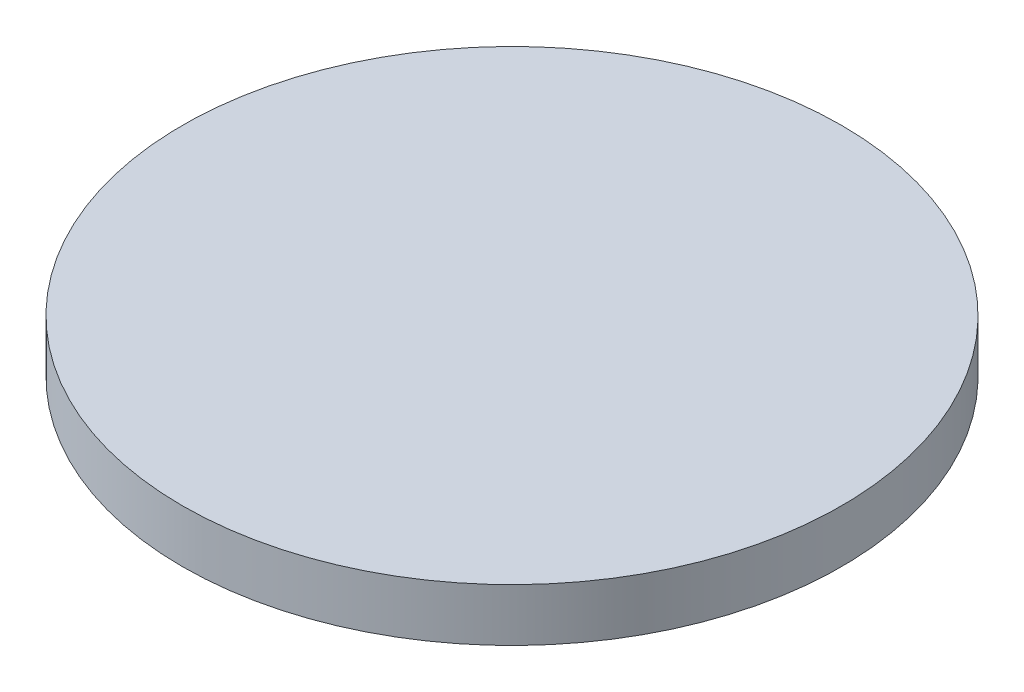
from build123d import *

# Parameters (mm, degrees)
SKETCH1_R           = 25
BOSS_EXTRUDE1_DEPTH = 4


with BuildPart() as part:
    # Sketch1 → Boss-Extrude1 (new body)
    with BuildSketch(Plane(origin=(0, 0, 0), x_dir=(1, 0, 0), z_dir=(0, 1, 0))):
        Circle(SKETCH1_R)
    extrude(amount=BOSS_EXTRUDE1_DEPTH)


solid = part.part
